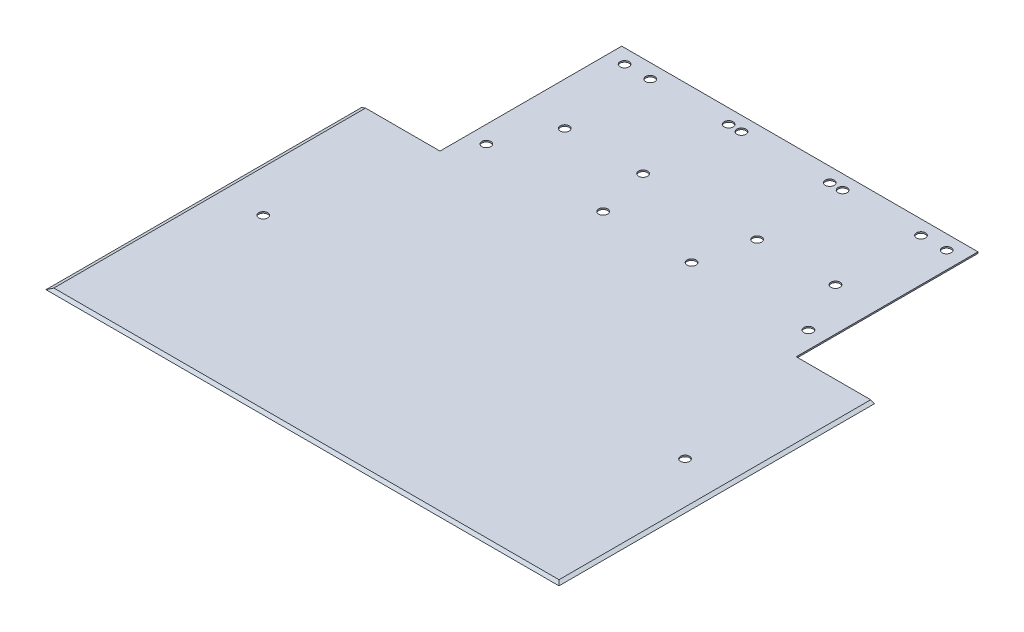
from build123d import *

# Parameters (mm, degrees)
SALIENTE_EXTRUIR1_DEPTH = 0.5
CORTAR_EXTRUIR4_REACH   = 2.5
CROQUIS6_R              = 1.585
CORTAR_EXTRUIR5_REACH   = 2.5
CROQUIS7_R              = 1.585
CROQUIS8_R              = 1.585
CORTAR_EXTRUIR6_DEPTH   = 0.5
CROQUIS9_R              = 1.585
CORTAR_EXTRUIR7_DEPTH   = 0.5
CROQUIS5_R              = 1.585
CORTAR_EXTRUIR8_DEPTH   = 0.5
CORTAR_EXTRUIR9_REACH   = 182
CORTAR_EXTRUIR10_START  = -110.74
CORTAR_EXTRUIR10_DEPTH  = 110.74


with BuildPart() as part:
    # Croquis2 → Saliente-Extruir1 (new body)
    with BuildSketch(Plane(origin=(0, 0, 0), x_dir=(1, 0, 0), z_dir=(0, 1, 0))):
        Polygon((-90, 25.54), (-62.5, 25.54), (-62.5, 89.31), (62.5, 89.31), (62.5, 25.54), (90, 25.54), (90, -85.2), (-90, -85.2), align=None)
    saliente_extruir1 = extrude(amount=SALIENTE_EXTRUIR1_DEPTH)

    # Croquis6 → Cortar-Extruir4 (cut, up to next)
    with BuildSketch(Plane(origin=(0, 0.5, 0), x_dir=(1, 0, 0), z_dir=(0, 1, 0)), mode=Mode.PRIVATE) as cortar_extruir4_sk1:
        with Locations((-56.5, 35.81)):
            Circle(CROQUIS6_R)
    cortar_extruir4_tool1 = extrude(cortar_extruir4_sk1.sketch, amount=-CORTAR_EXTRUIR4_REACH, mode=Mode.PRIVATE) & part.part
    add(cortar_extruir4_tool1.solids().sort_by_distance((-56.5, 0.5, -35.81))[0], mode=Mode.SUBTRACT)
    # Croquis6 → Cortar-Extruir4 (cut, up to next)
    with BuildSketch(Plane(origin=(0, 0.5, 0), x_dir=(1, 0, 0), z_dir=(0, 1, 0)), mode=Mode.PRIVATE) as cortar_extruir4_sk2:
        with Locations((-15.5, 35.81)):
            Circle(CROQUIS6_R)
    cortar_extruir4_tool2 = extrude(cortar_extruir4_sk2.sketch, amount=-CORTAR_EXTRUIR4_REACH, mode=Mode.PRIVATE) & part.part
    add(cortar_extruir4_tool2.solids().sort_by_distance((-15.5, 0.5, -35.81))[0], mode=Mode.SUBTRACT)
    # Croquis6 → Cortar-Extruir4 (cut, up to next)
    with BuildSketch(Plane(origin=(0, 0.5, 0), x_dir=(1, 0, 0), z_dir=(0, 1, 0)), mode=Mode.PRIVATE) as cortar_extruir4_sk3:
        with Locations((-15.5, 84.31)):
            Circle(CROQUIS6_R)
    cortar_extruir4_tool3 = extrude(cortar_extruir4_sk3.sketch, amount=-CORTAR_EXTRUIR4_REACH, mode=Mode.PRIVATE) & part.part
    add(cortar_extruir4_tool3.solids().sort_by_distance((-15.5, 0.5, -84.31))[0], mode=Mode.SUBTRACT)
    # Croquis6 → Cortar-Extruir4 (cut, up to next)
    with BuildSketch(Plane(origin=(0, 0.5, 0), x_dir=(1, 0, 0), z_dir=(0, 1, 0)), mode=Mode.PRIVATE) as cortar_extruir4_sk4:
        with Locations((-56.5, 84.31)):
            Circle(CROQUIS6_R)
    cortar_extruir4_tool4 = extrude(cortar_extruir4_sk4.sketch, amount=-CORTAR_EXTRUIR4_REACH, mode=Mode.PRIVATE) & part.part
    add(cortar_extruir4_tool4.solids().sort_by_distance((-56.5, 0.5, -84.31))[0], mode=Mode.SUBTRACT)

    # Croquis7 → Cortar-Extruir5 (cut, up to next)
    with BuildSketch(Plane(origin=(0, 0.5, 0), x_dir=(1, 0, 0), z_dir=(0, 1, 0)), mode=Mode.PRIVATE) as cortar_extruir5_sk1:
        with Locations((56.5, 35.81)):
            Circle(CROQUIS7_R)
    cortar_extruir5_tool1 = extrude(cortar_extruir5_sk1.sketch, amount=-CORTAR_EXTRUIR5_REACH, mode=Mode.PRIVATE) & part.part
    add(cortar_extruir5_tool1.solids().sort_by_distance((56.5, 0.5, -35.81))[0], mode=Mode.SUBTRACT)
    # Croquis7 → Cortar-Extruir5 (cut, up to next)
    with BuildSketch(Plane(origin=(0, 0.5, 0), x_dir=(1, 0, 0), z_dir=(0, 1, 0)), mode=Mode.PRIVATE) as cortar_extruir5_sk2:
        with Locations((15.5, 35.81)):
            Circle(CROQUIS7_R)
    cortar_extruir5_tool2 = extrude(cortar_extruir5_sk2.sketch, amount=-CORTAR_EXTRUIR5_REACH, mode=Mode.PRIVATE) & part.part
    add(cortar_extruir5_tool2.solids().sort_by_distance((15.5, 0.5, -35.81))[0], mode=Mode.SUBTRACT)
    # Croquis7 → Cortar-Extruir5 (cut, up to next)
    with BuildSketch(Plane(origin=(0, 0.5, 0), x_dir=(1, 0, 0), z_dir=(0, 1, 0)), mode=Mode.PRIVATE) as cortar_extruir5_sk3:
        with Locations((15.5, 84.31)):
            Circle(CROQUIS7_R)
    cortar_extruir5_tool3 = extrude(cortar_extruir5_sk3.sketch, amount=-CORTAR_EXTRUIR5_REACH, mode=Mode.PRIVATE) & part.part
    add(cortar_extruir5_tool3.solids().sort_by_distance((15.5, 0.5, -84.31))[0], mode=Mode.SUBTRACT)
    # Croquis7 → Cortar-Extruir5 (cut, up to next)
    with BuildSketch(Plane(origin=(0, 0.5, 0), x_dir=(1, 0, 0), z_dir=(0, 1, 0)), mode=Mode.PRIVATE) as cortar_extruir5_sk4:
        with Locations((56.5, 84.31)):
            Circle(CROQUIS7_R)
    cortar_extruir5_tool4 = extrude(cortar_extruir5_sk4.sketch, amount=-CORTAR_EXTRUIR5_REACH, mode=Mode.PRIVATE) & part.part
    add(cortar_extruir5_tool4.solids().sort_by_distance((56.5, 0.5, -84.31))[0], mode=Mode.SUBTRACT)

    # Simetría3: Saliente-Extruir1 across plane
    add(saliente_extruir1.mirror(Plane(origin=(0, 0, 0), x_dir=(0, 0, 1), z_dir=(1, 0, 0))))

    # Croquis8 → Cortar-Extruir6 (cut)
    with BuildSketch(Plane(origin=(0, 0.5, 0), x_dir=(1, 0, 0), z_dir=(0, 1, 0))):
        with Locations((-20, 54.31)):
            Circle(CROQUIS8_R)
        with Locations((-47.5, 54.31)):
            Circle(CROQUIS8_R)
        with Locations((-47.5, 84.31)):
            Circle(CROQUIS8_R)
        with Locations((-20, 84.31)):
            Circle(CROQUIS8_R)
    cortar_extruir6 = extrude(amount=-CORTAR_EXTRUIR6_DEPTH, mode=Mode.SUBTRACT)

    # Simetría4: Cortar-Extruir6 across plane
    add(cortar_extruir6.mirror(Plane(origin=(0, 0, 0), x_dir=(0, 0, 1), z_dir=(1, 0, 0))), mode=Mode.SUBTRACT)

    # Croquis9 → Cortar-Extruir7 (cut)
    with BuildSketch(Plane.XZ):
        with Locations((56.5, -35.81)):
            Circle(CROQUIS9_R)
        with Locations((15.5, -35.81)):
            Circle(CROQUIS9_R)
        with Locations((15.5, -84.31)):
            Circle(CROQUIS9_R)
        with Locations((56.5, -84.31)):
            Circle(CROQUIS9_R)
    cortar_extruir7 = extrude(amount=-CORTAR_EXTRUIR7_DEPTH, mode=Mode.SUBTRACT)

    # Simetría5: Cortar-Extruir7 across plane
    add(cortar_extruir7.mirror(Plane(origin=(0, 0, 0), x_dir=(0, 0, 1), z_dir=(1, 0, 0))), mode=Mode.SUBTRACT)

    # Croquis5 → Cortar-Extruir8 (cut)
    with BuildSketch(Plane(origin=(0, 0.5, 0), x_dir=(1, 0, 0), z_dir=(0, 1, 0))):
        with Locations((74, -24.969940997)):
            Circle(CROQUIS5_R)
    cortar_extruir8 = extrude(amount=-CORTAR_EXTRUIR8_DEPTH, mode=Mode.SUBTRACT)

    # Simetría6: Cortar-Extruir8 across plane
    add(cortar_extruir8.mirror(Plane(origin=(0, 0, 0), x_dir=(0, 0, 1), z_dir=(1, 0, 0))), mode=Mode.SUBTRACT)

    # Croquis3 → Cortar-Extruir9 (cut, up to next)
    with BuildSketch(Plane(origin=(90, 0, 0), x_dir=(0, 0, -1), z_dir=(1, 0, 0)), mode=Mode.PRIVATE) as cortar_extruir9_sk1:
        Polygon((-85.2, 0), (-83.82626129, 0.5), (-85.2, 0.5), align=None)
    cortar_extruir9_tool1 = extrude(cortar_extruir9_sk1.sketch, amount=-CORTAR_EXTRUIR9_REACH, mode=Mode.PRIVATE) & part.part
    add(cortar_extruir9_tool1.solids().sort_by_distance((90, 0.333333, 84.742087))[0], mode=Mode.SUBTRACT)

    # Croquis10 → Cortar-Extruir10 (cut)
    with BuildSketch(Plane(origin=(0, 0, -25.54), x_dir=(-1, 0, 0), z_dir=(0, 0, -1)).offset(CORTAR_EXTRUIR10_START)):
        Polygon((90, 0), (90, 0.5), (88.62626129, 0.5), align=None)
    cortar_extruir10 = extrude(amount=CORTAR_EXTRUIR10_DEPTH, mode=Mode.SUBTRACT)

    # Simetría7: Cortar-Extruir10 across plane
    add(cortar_extruir10.mirror(Plane(origin=(0, 0, 0), x_dir=(0, 0, 1), z_dir=(1, 0, 0))), mode=Mode.SUBTRACT)


solid = part.part
